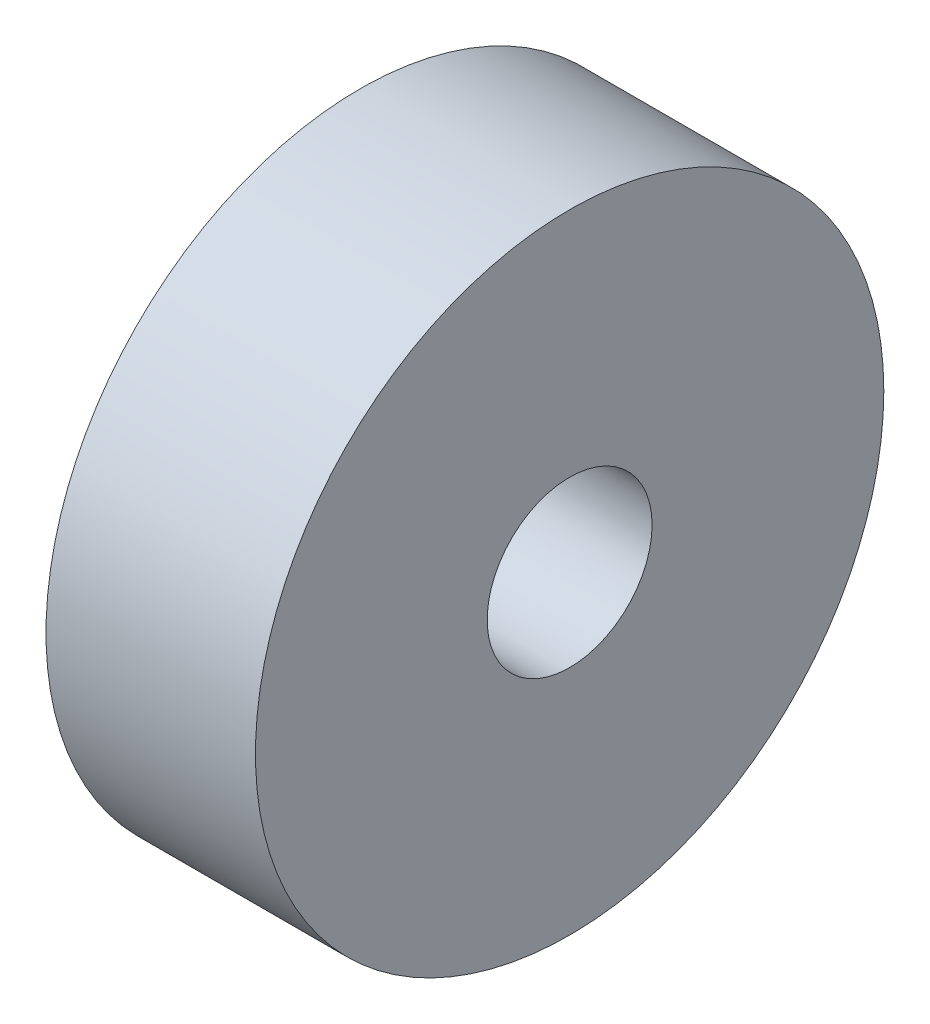
from build123d import *

# Parameters (mm, degrees)
SKETCH1_R           = 19.05
SKETCH1_R_2         = 5
BOSS_EXTRUDE1_DEPTH = 12.7


with BuildPart() as part:
    # Sketch1 → Boss-Extrude1 (new body)
    with BuildSketch(Plane(origin=(0, 0, 0), x_dir=(0, 0, -1), z_dir=(1, 0, 0))):
        Circle(SKETCH1_R)
        Circle(SKETCH1_R_2, mode=Mode.SUBTRACT)
    extrude(amount=BOSS_EXTRUDE1_DEPTH)


solid = part.part
